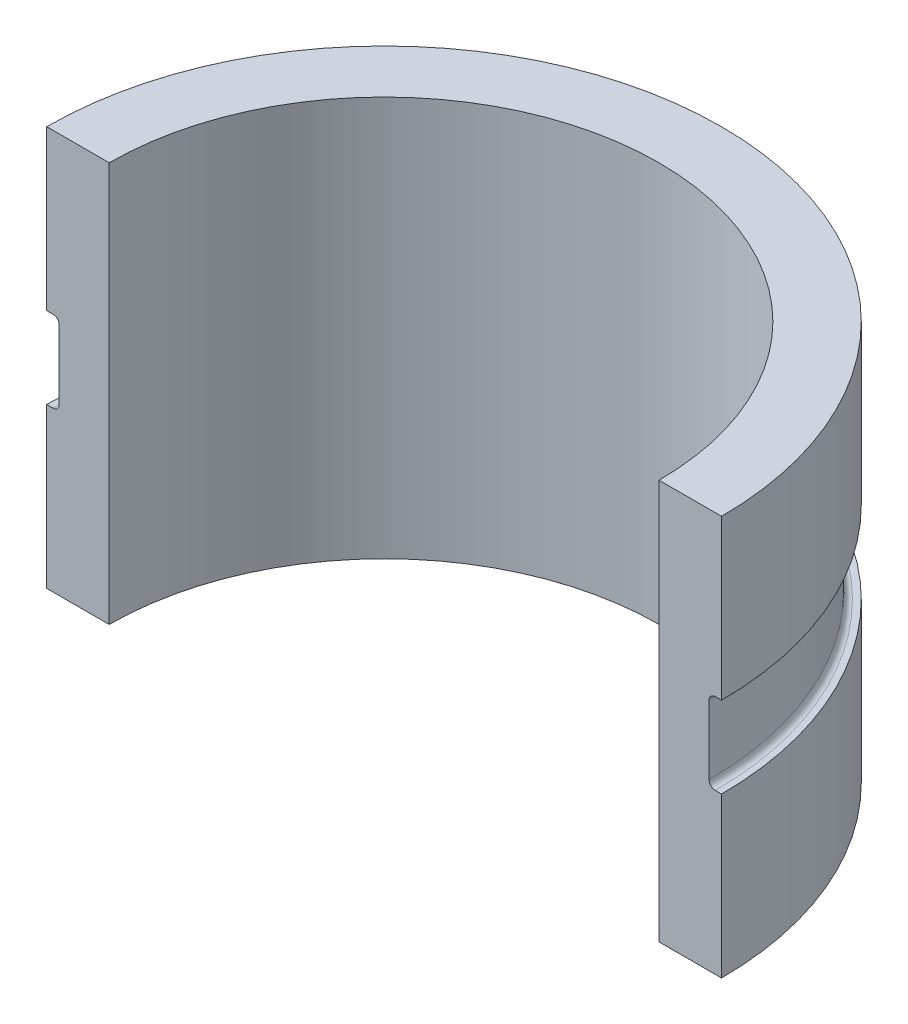
from build123d import *

# Parameters (mm, degrees)
BOSS_EXTRUDE1_DEPTH = 81.28
SKETCH2_W           = 2.54
SKETCH2_H           = 16.51
CUT_REVOLVE1_ANGLE  = 180
FILLET1_R           = 1.27


with BuildPart() as part:
    # Sketch1 → Boss-Extrude1 (new body)
    with BuildSketch(Plane(origin=(0, 0, 0), x_dir=(1, 0, 0), z_dir=(0, 1, 0))):
        with BuildLine():
            Line((-68.58, 0), (-55.88, 0))
            ThreePointArc((-55.88, 0), (0, 55.88), (55.88, 0))
            Line((55.88, 0), (68.58, 0))
            ThreePointArc((68.58, 0), (0, 68.58), (-68.58, 0))
        make_face()
    extrude(amount=BOSS_EXTRUDE1_DEPTH)

    # Sketch2 → Cut-Revolve1 (revolve, cut)
    with BuildSketch(Plane.XY):
        with Locations((-67.31, 40.64)):
            Rectangle(SKETCH2_W, SKETCH2_H)
    revolve(axis=Axis((0, 81.28, 0), (0, -1, 0)), revolution_arc=CUT_REVOLVE1_ANGLE, mode=Mode.SUBTRACT)

    # Fillet1
    fillet1_edges = [part.edges().sort_by_distance(p)[0] for p in [
        (0, 48.895, -66.04),
        (0, 32.385, -66.04),
    ]]
    fillet(fillet1_edges, radius=FILLET1_R)


solid = part.part
